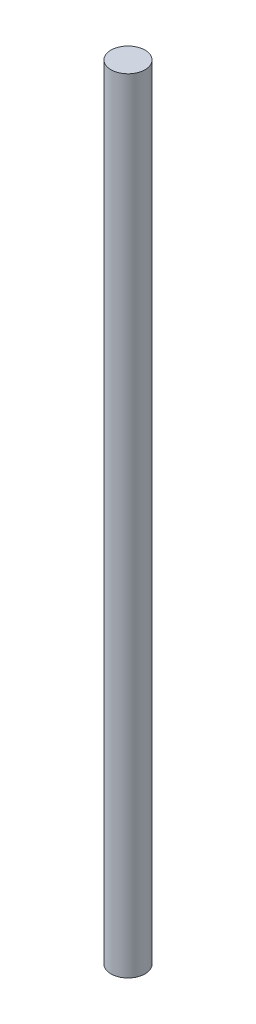
from build123d import *

# Parameters (mm, degrees)
SKETCH1_R           = 3.175
BOSS_EXTRUDE1_DEPTH = 146.05


with BuildPart() as part:
    # Sketch1 → Boss-Extrude1 (new body)
    with BuildSketch(Plane(origin=(0, 0, 0), x_dir=(1, 0, 0), z_dir=(0, 1, 0))):
        Circle(SKETCH1_R)
    extrude(amount=BOSS_EXTRUDE1_DEPTH)


solid = part.part
